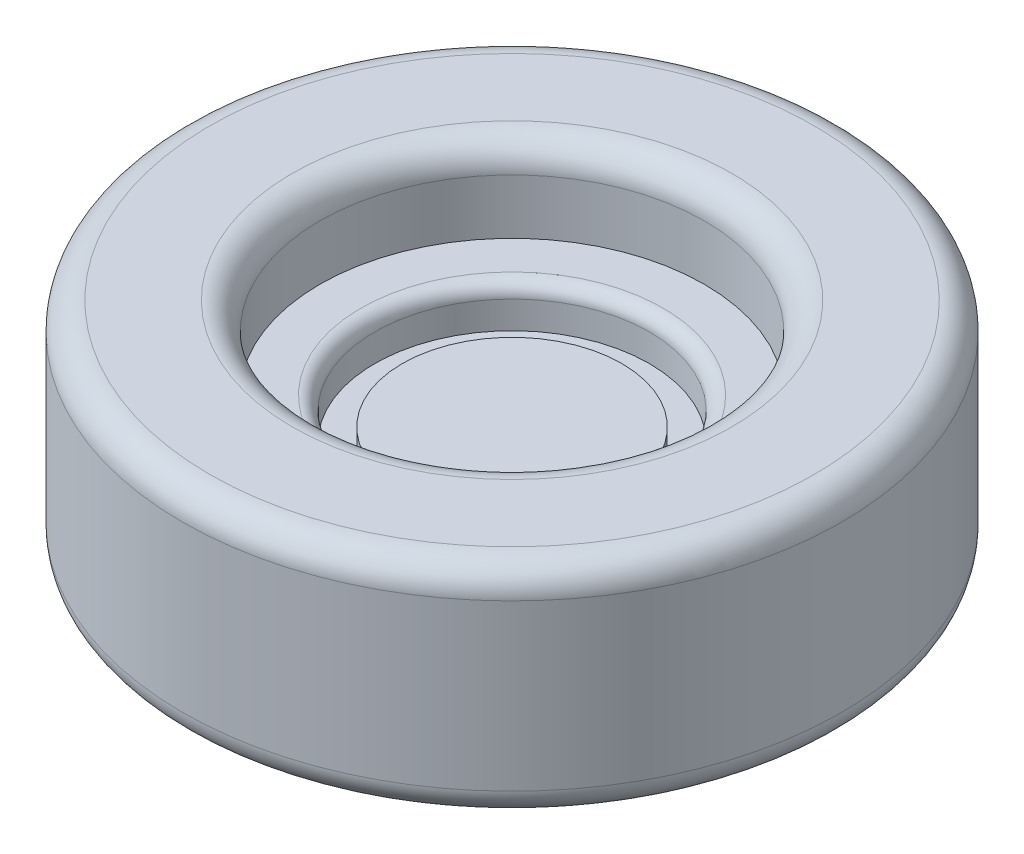
from build123d import *

# Parameters (mm, degrees)
SKETCH_1_W          = 40
SKETCH_1_H          = 15
EXTRUDE_1_DEPTH     = 1.5
SKETCH_2_R          = 12
EXTRUDE_2_DEPTH     = 8
SKETCH_3_R          = 7
SKETCH_3_R_2        = 5
CUT_EXTRUDE_1_DEPTH = 3
SKETCH_4_R          = 5
CUT_EXTRUDE_2_DEPTH = 4.5
SKETCH_5_R          = 4
EXTRUDE_3_DEPTH     = 0.5
FILLET_3_R          = 1
FILLET_5_R          = 0.5
SKETCH_6_W          = 15
SKETCH_6_H          = 1.5
CUT_EXTRUDE_3_DEPTH = 41
FILLET_6_R          = 1
SKETCH_7_W          = 5
SKETCH_7_H          = 5
CUT_EXTRUDE_4_DEPTH = 1.5


with BuildPart() as part:
    # 草图1 → 凸台-拉伸1 (new body)
    with BuildSketch(Plane(origin=(0, 0, 0), x_dir=(1, 0, 0), z_dir=(0, 1, 0))):
        Rectangle(SKETCH_1_W, SKETCH_1_H)
    extrude(amount=EXTRUDE_1_DEPTH)

    # 草图2 → 凸台-拉伸2 (add)
    with BuildSketch(Plane(origin=(0, 1.5, 0), x_dir=(1, 0, 0), z_dir=(0, 1, 0))):
        Circle(SKETCH_2_R)
    extrude(amount=EXTRUDE_2_DEPTH)

    # 草图3 → 切除-拉伸1 (cut)
    with BuildSketch(Plane(origin=(0, 9.5, 0), x_dir=(1, 0, 0), z_dir=(0, 1, 0))):
        Circle(SKETCH_3_R)
        Circle(SKETCH_3_R_2, mode=Mode.SUBTRACT)
    extrude(amount=-CUT_EXTRUDE_1_DEPTH, mode=Mode.SUBTRACT)

    # 草图4 → 切除-拉伸2 (cut)
    with BuildSketch(Plane(origin=(0, 9.5, 0), x_dir=(1, 0, 0), z_dir=(0, 1, 0))):
        Circle(SKETCH_4_R)
    extrude(amount=-CUT_EXTRUDE_2_DEPTH, mode=Mode.SUBTRACT)

    # 草图5 → 凸台-拉伸3 (add)
    with BuildSketch(Plane(origin=(0, 5, 0), x_dir=(1, 0, 0), z_dir=(0, 1, 0))):
        Circle(SKETCH_5_R)
    extrude(amount=EXTRUDE_3_DEPTH)

    # 圆角3
    fillet_3_edges = [part.edges().sort_by_distance(p)[0] for p in [
        (-12, 9.5, 0),
        (-7, 9.5, 0),
    ]]
    fillet(fillet_3_edges, radius=FILLET_3_R)

    # 圆角5
    fillet_5_edges = [part.edges().sort_by_distance(p)[0] for p in [
        (-5, 6.5, 0),
    ]]
    fillet(fillet_5_edges, radius=FILLET_5_R)

    # 草图6 → 切除-拉伸3 (cut, through all)
    with BuildSketch(Plane(origin=(20, 0, 0), x_dir=(0, 0, -1), z_dir=(1, 0, 0))):
        with Locations((0, 0.75)):
            Rectangle(SKETCH_6_W, SKETCH_6_H)
    extrude(amount=-CUT_EXTRUDE_3_DEPTH, mode=Mode.SUBTRACT)

    # 圆角6
    fillet_6_edges = [part.edges().sort_by_distance(p)[0] for p in [
        (-12, 1.5, 0),
    ]]
    fillet(fillet_6_edges, radius=FILLET_6_R)

    # 草图7 → 切除-拉伸4 (cut)
    with BuildSketch(Plane.XZ.offset(-1.5)):
        Rectangle(SKETCH_7_W, SKETCH_7_H)
    extrude(amount=-CUT_EXTRUDE_4_DEPTH, mode=Mode.SUBTRACT)


solid = part.part
